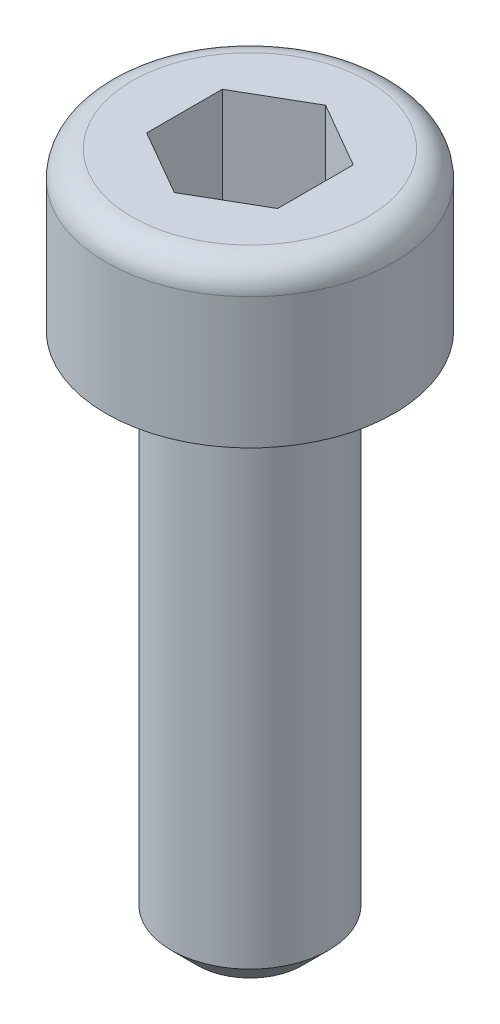
from build123d import *

# Parameters (mm, degrees)
CORTAR_EXTRUIR1_DEPTH = 2
CHAFL_N1_SIZE         = 0.5
REDONDEO1_R           = 0.5


with BuildPart() as part:
    # Croquis1 → Revolución1 (revolve)
    with BuildSketch(Plane.XY):
        Polygon((0, 0), (2.75, 0), (2.75, -3), (1.5, -3), (1.5, -13), (0, -13), align=None)
    revolve(axis=Axis((0, 0, 0), (0, -1, 0)))

    # Croquis2 → Cortar-Extruir1 (cut)
    with BuildSketch(Plane(origin=(0, 0, 0), x_dir=(1, 0, 0), z_dir=(0, 1, 0))):
        Polygon((1.25, 0.721687836), (0, 1.443375673), (-1.25, 0.721687836), (-1.25, -0.721687836), (0, -1.443375673), (1.25, -0.721687836), align=None)
    extrude(amount=-CORTAR_EXTRUIR1_DEPTH, mode=Mode.SUBTRACT)

    # Chaflán1
    chafl_n1_edges = [part.edges().sort_by_distance(p)[0] for p in [
        (-1.5, -13, 0),
    ]]
    chamfer(chafl_n1_edges, length=CHAFL_N1_SIZE)

    # Redondeo1
    redondeo1_edges = [part.edges().sort_by_distance(p)[0] for p in [
        (-2.75, 0, 0),
    ]]
    fillet(redondeo1_edges, radius=REDONDEO1_R)


solid = part.part
